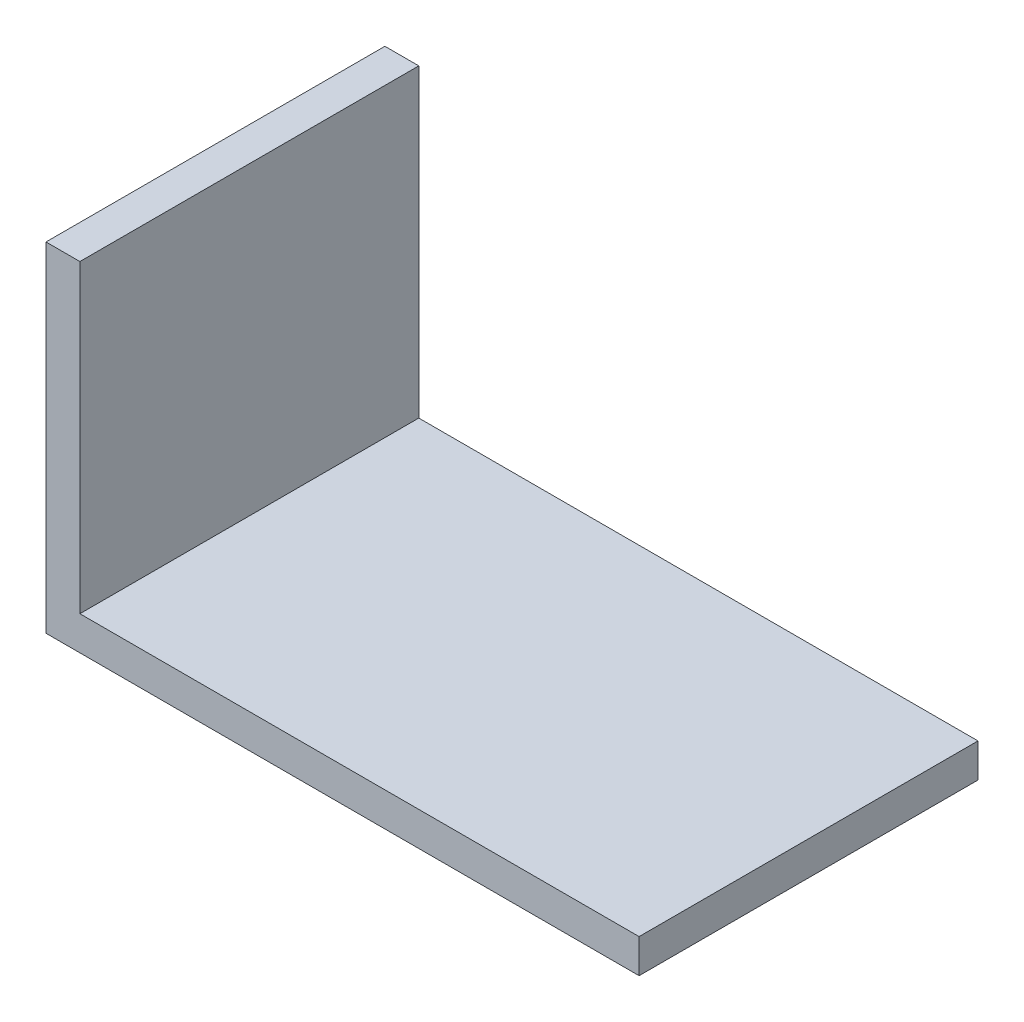
from build123d import *

# Parameters (mm, degrees)
EXTRUDE_1_DEPTH = 20


with BuildPart() as part:
    # Эскиз1 → Бобышка-Вытянуть1 (new body)
    with BuildSketch(Plane.XY):
        Polygon((0, 0), (35, 0), (35, 2), (2, 2), (2, 20), (0, 20), align=None)
    extrude(amount=EXTRUDE_1_DEPTH)


solid = part.part
